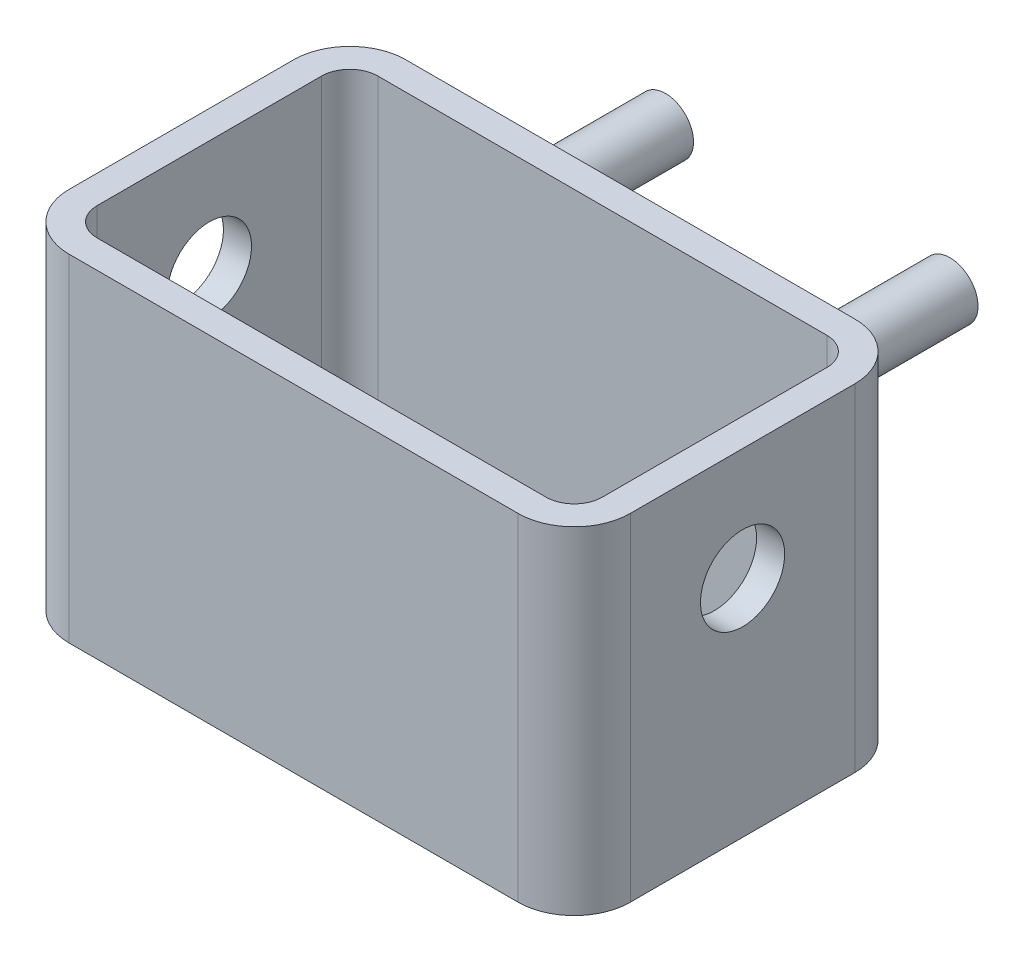
from build123d import *

# Parameters (mm, degrees)
SKICA1_W                 = 100
SKICA1_H                 = 60
VYSUNOUT1_DEPTH          = 60
ZAOBLIT1_R               = 10
SKO_EPINA1_T             = -5
SKICA2_R                 = 7.5
ODEBRAT_VYSUNUT_M2_DEPTH = 101
SKICA3_R                 = 5
VYSUNOUT2_DEPTH          = 30


with BuildPart() as part:
    # Skica1 → Vysunout1 (new body)
    with BuildSketch(Plane.XY):
        with Locations((50, 30)):
            Rectangle(SKICA1_W, SKICA1_H)
    extrude(amount=VYSUNOUT1_DEPTH)

    # Zaoblit1
    zaoblit1_edges = [part.edges().sort_by_distance(p)[0] for p in [
        (100, 30, 60),
        (0, 30, 60),
        (100, 30, 0),
        (0, 30, 0),
    ]]
    fillet(zaoblit1_edges, radius=ZAOBLIT1_R)

    # Skořepina1
    sko_epina1_openings = [part.faces().sort_by_distance(p)[0] for p in [
        (50, 60, 30),
    ]]
    offset(amount=SKO_EPINA1_T, openings=sko_epina1_openings, kind=Kind.INTERSECTION)

    # Skica2 → Odebrat vysunutím2 (cut, through all)
    with BuildSketch(Plane(origin=(100, 0, 0), x_dir=(0, 0, -1), z_dir=(1, 0, 0))):
        with Locations((-30, 40)):
            Circle(SKICA2_R)
    extrude(amount=-ODEBRAT_VYSUNUT_M2_DEPTH, mode=Mode.SUBTRACT)

    # Skica3 → Vysunout2 (add)
    with BuildSketch(Plane(origin=(0, 0, 0), x_dir=(-1, 0, 0), z_dir=(0, 0, -1))):
        with Locations((-76.959009894, 42.942278301)):
            Circle(SKICA3_R)
        with Locations((-26.264349984, 42.942278301)):
            Circle(SKICA3_R)
    extrude(amount=VYSUNOUT2_DEPTH)


solid = part.part
